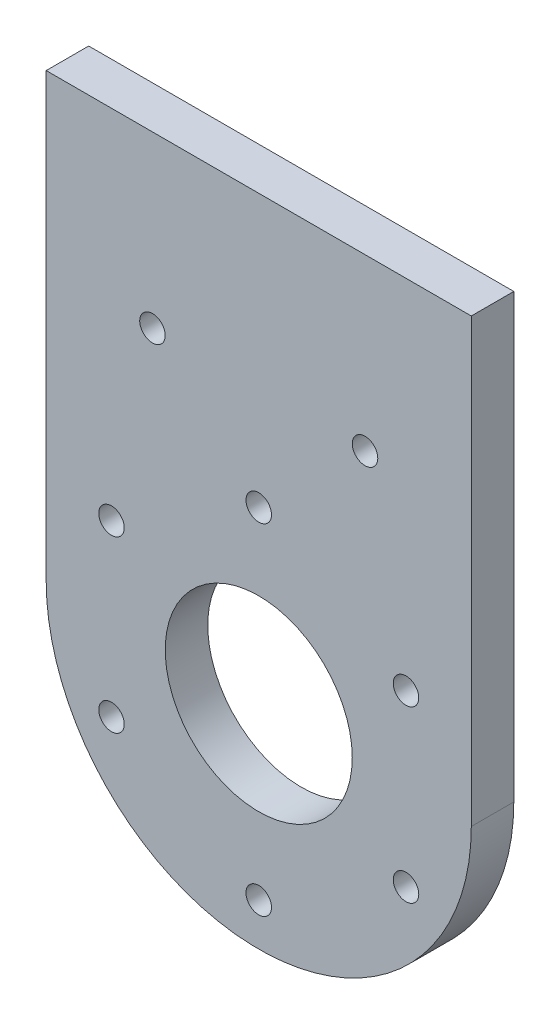
from build123d import *

# Parameters (mm, degrees)
ESQUISSE1_W             = 100
ESQUISSE1_H             = 100.548113933
ESQUISSE1_R             = 11
BOSS_EXTRU_1_DEPTH      = 5
ESQUISSE2_R             = 1.5
ENL_V_MAT_EXTRU_1_DEPTH = 73.311824759


with BuildPart() as part:
    # Esquisse1 → Boss.-Extru.1 (new body)
    with BuildSketch(Plane.XY):
        with Locations((0, 1.725943033)):
            Rectangle(ESQUISSE1_W, ESQUISSE1_H)
        Circle(ESQUISSE1_R, mode=Mode.SUBTRACT)
    extrude(amount=BOSS_EXTRU_1_DEPTH)

    # Esquisse2 → Enlèv. mat.-Extru.1 (cut, through all)
    with BuildSketch(Plane.XY.offset(5)):
        with BuildLine():
            Line((25, 52), (25, 0))
            ThreePointArc((25, 0), (0, -25), (-25, 0))
            Line((-25, 0), (-25, 52))
            Line((-25, 52), (-50, 52))
            Line((-50, 52), (-50, -48.548113933))
            Line((-50, -48.548113933), (50, -48.548113933))
            Line((50, -48.548113933), (50, 52))
            Line((50, 52), (25, 52))
        make_face()
        with Locations((0, 20)):
            Circle(ESQUISSE2_R)
        with Locations((17.320508076, 10)):
            Circle(ESQUISSE2_R)
        with Locations((17.320508076, -10)):
            Circle(ESQUISSE2_R)
        with Locations((0, -20)):
            Circle(ESQUISSE2_R)
        with Locations((-17.320508076, -10)):
            Circle(ESQUISSE2_R)
        with Locations((-17.320508076, 10)):
            Circle(ESQUISSE2_R)
        with Locations((-12.5, 32)):
            Circle(ESQUISSE2_R)
        with Locations((12.5, 32)):
            Circle(ESQUISSE2_R)
    extrude(amount=-ENL_V_MAT_EXTRU_1_DEPTH, mode=Mode.SUBTRACT)


solid = part.part
